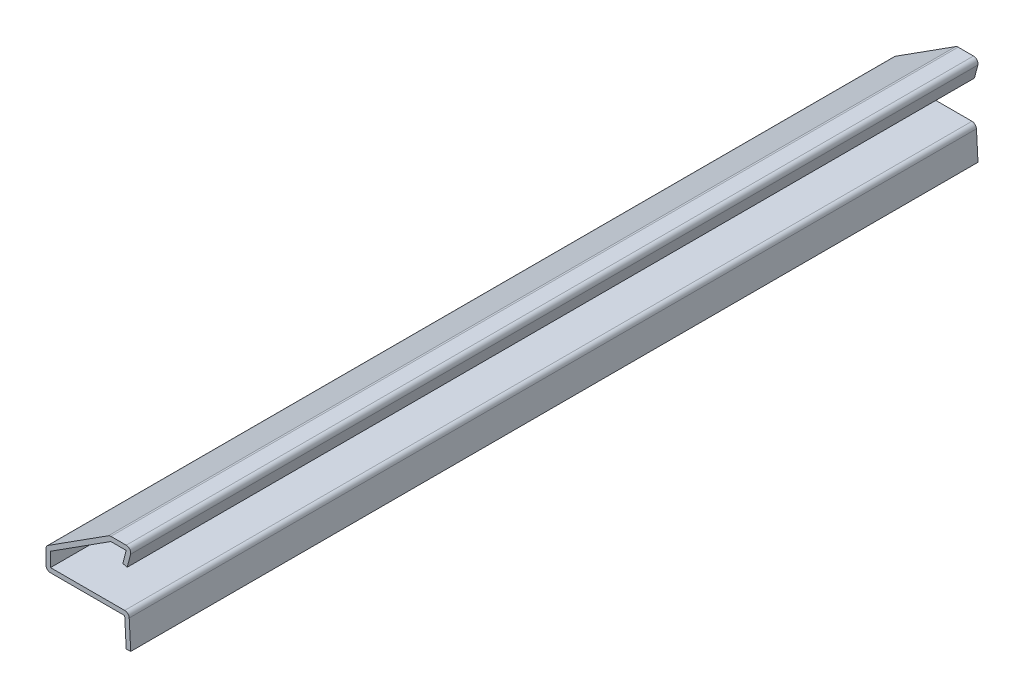
from build123d import *

# Parameters (mm, degrees)
BOSS_EXTRUDE1_DEPTH = 190.5
FILLET1_R           = 1.016


with BuildPart() as part:
    # Sketch1 → Boss-Extrude1 (new body)
    with BuildSketch(Plane.XY):
        with BuildLine():
            Line((-1.014506285, -0.055072655), (-1.359217172, 6.294927345))
            Line((-1.359217172, 6.294927345), (-19.05, 6.294927345))
            Line((-19.05, 6.294927345), (-19.05, 11.057427345))
            Line((-19.05, 11.057427345), (-4.7625, 20.185552345))
            Line((-4.7625, 20.185552345), (-1.016, 20.185552345))
            ThreePointArc((-1.016, 20.185552345), (-0.212054439, 19.790783006), (-0.032858991, 18.913252215))
            Line((-0.032858991, 18.913252215), (-0.79375, 15.994552345))
            Line((-0.79375, 15.994552345), (-1.776891009, 16.250852474))
            Line((-1.776891009, 16.250852474), (-1.016, 19.169552345))
            Line((-1.016, 19.169552345), (-4.465650477, 19.169552345))
            Line((-4.465650477, 19.169552345), (-18.034, 10.500884594))
            Line((-18.034, 10.500884594), (-18.034, 7.310927345))
            Line((-18.034, 7.310927345), (-0.396875, 7.310927345))
            Line((-0.396875, 7.310927345), (0, 0))
            Line((0, 0), (-1.014506285, -0.055072655))
        make_face()
    extrude(amount=-BOSS_EXTRUDE1_DEPTH)

    # Fillet1
    fillet1_edges = [part.edges().sort_by_distance(p)[0] for p in [
        (-19.05, 6.294927345, -95.25),
        (-19.05, 11.057427345, -95.25),
        (-4.7625, 20.185552345, -95.25),
        (-0.396875, 7.310927345, -95.25),
    ]]
    fillet(fillet1_edges, radius=FILLET1_R)


solid = part.part
